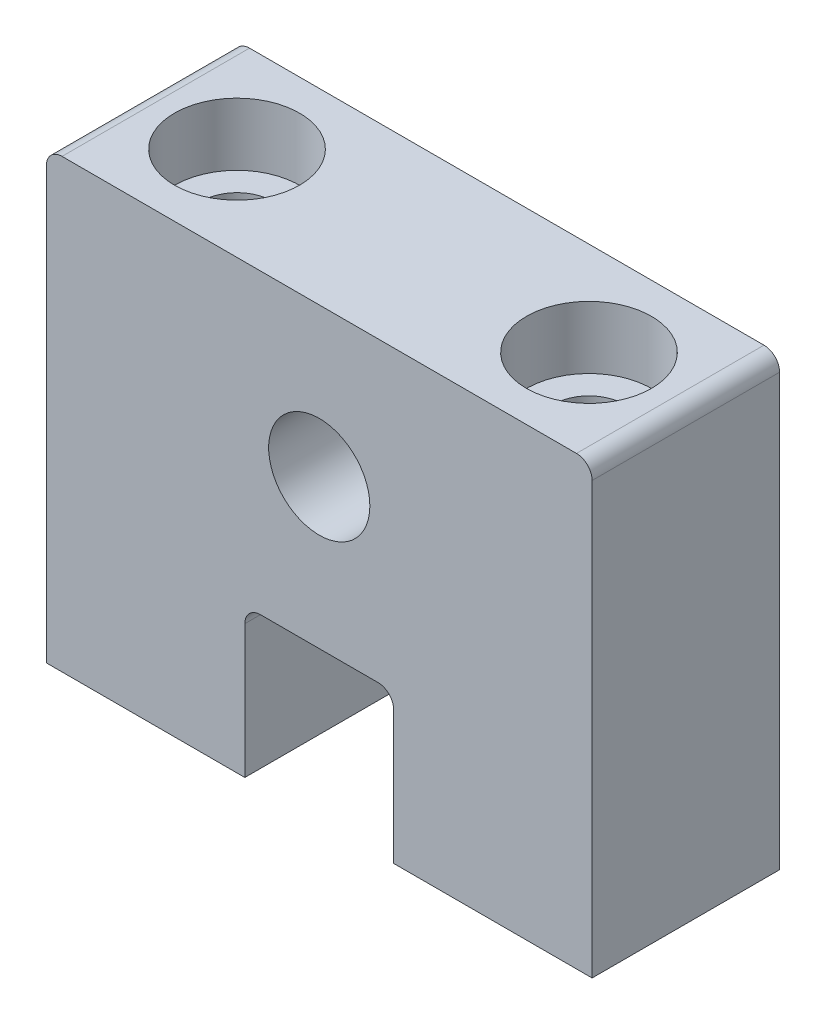
from build123d import *

# Parameters (mm, degrees)
SKETCH1_R                      = 3.2385
BOSS_EXTRUDE1_DEPTH            = 12
CBORE_FOR_M4_SHCS1_D           = 4.5
CBORE_FOR_M4_SHCS1_CBORE_D     = 8
CBORE_FOR_M4_SHCS1_CBORE_DEPTH = 4
FILLET1_R                      = 1


with BuildPart() as part:
    # Sketch1 → Boss-Extrude1 (new body)
    with BuildSketch(Plane.XY):
        Polygon((-17.4625, 28.575), (17.4625, 28.575), (17.4625, 0), (4.7625, 0), (4.7625, 9.525), (-4.7625, 9.525), (-4.7625, 0), (-17.4625, 0), align=None)
        with Locations((0, 19.05)):
            Circle(SKETCH1_R, mode=Mode.SUBTRACT)
    extrude(amount=BOSS_EXTRUDE1_DEPTH)

    # CBORE for M4 SHCS1 (through all)
    with Locations(Plane(origin=(0, 28.575, 0), x_dir=(1, 0, 0), z_dir=(0, 1, 0))):
        with Locations((-11.2625, -6), (11.2625, -6)):
            CounterBoreHole(CBORE_FOR_M4_SHCS1_D / 2, CBORE_FOR_M4_SHCS1_CBORE_D / 2, CBORE_FOR_M4_SHCS1_CBORE_DEPTH)

    # Fillet1
    fillet1_edges = [part.edges().sort_by_distance(p)[0] for p in [
        (4.7625, 9.525, 6),
        (-4.7625, 9.525, 6),
        (-17.4625, 28.575, 6),
        (17.4625, 28.575, 6),
    ]]
    fillet(fillet1_edges, radius=FILLET1_R)


solid = part.part
